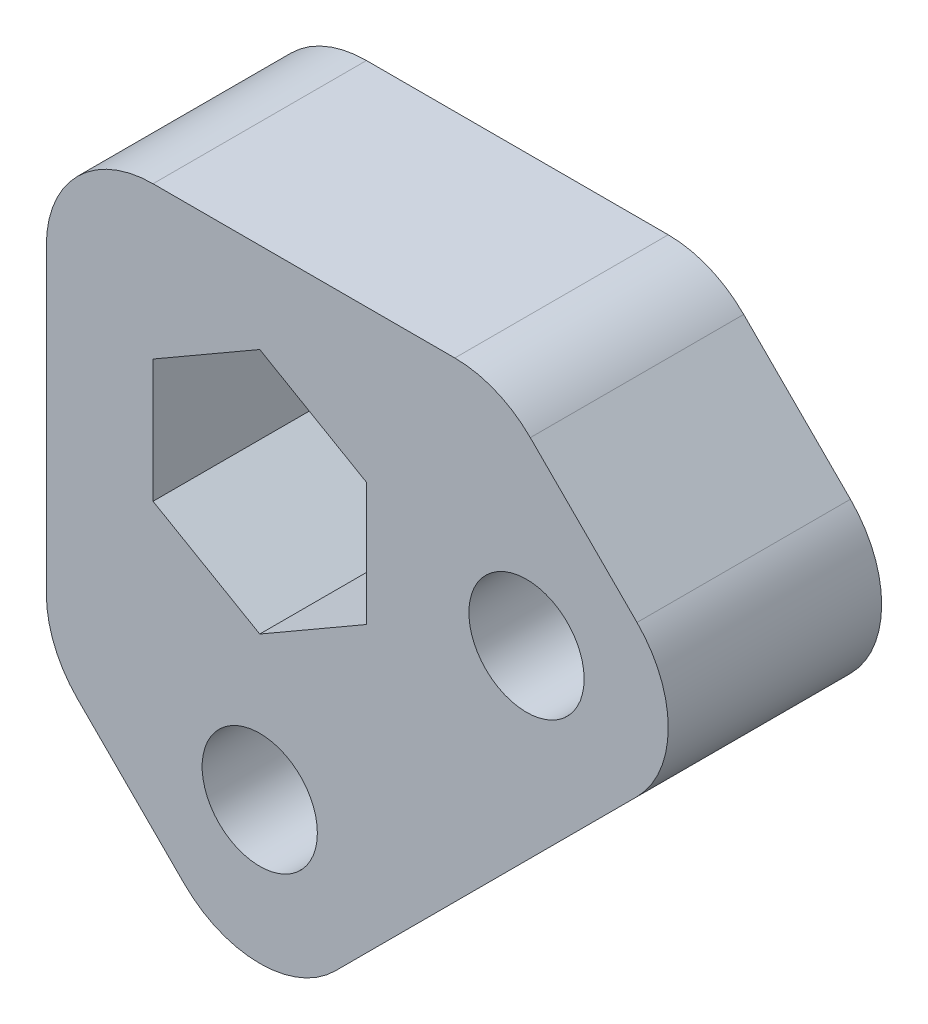
from build123d import *

# Parameters (mm, degrees)
SKETCH2_R           = 3.429
BOSS_EXTRUDE1_DEPTH = 12.7


with BuildPart() as part:
    # Sketch2 → Boss-Extrude1 (new body)
    with BuildSketch(Plane.XY):
        with BuildLine():
            Line((-10.840128061, -16.100640303), (-4.490128061, -22.450640303))
            ThreePointArc((-4.490128061, -22.450640303), (0, -24.310512242), (4.490128061, -22.450640303))
            Line((4.490128061, -22.450640303), (22.450640303, -4.490128061))
            ThreePointArc((22.450640303, -4.490128061), (24.310512242, 0), (22.450640303, 4.490128061))
            Line((22.450640303, 4.490128061), (16.100640303, 10.840128061))
            ThreePointArc((16.100640303, 10.840128061), (14.040552038, 12.216635031), (11.610512242, 12.7))
            Line((11.610512242, 12.7), (-6.35, 12.7))
            ThreePointArc((-6.35, 12.7), (-10.840128061, 10.840128061), (-12.7, 6.35))
            Line((-12.7, 6.35), (-12.7, -11.610512242))
            ThreePointArc((-12.7, -11.610512242), (-12.216635031, -14.040552038), (-10.840128061, -16.100640303))
        make_face()
        with Locations((15.875, 0)):
            Circle(SKETCH2_R, mode=Mode.SUBTRACT)
        with Locations((0, -15.875)):
            Circle(SKETCH2_R, mode=Mode.SUBTRACT)
        Polygon((6.35, 3.666174209), (0, 7.332348419), (-6.35, 3.666174209), (-6.35, -3.666174209), (0, -7.332348419), (6.35, -3.666174209), align=None, mode=Mode.SUBTRACT)
    extrude(amount=BOSS_EXTRUDE1_DEPTH)


solid = part.part
